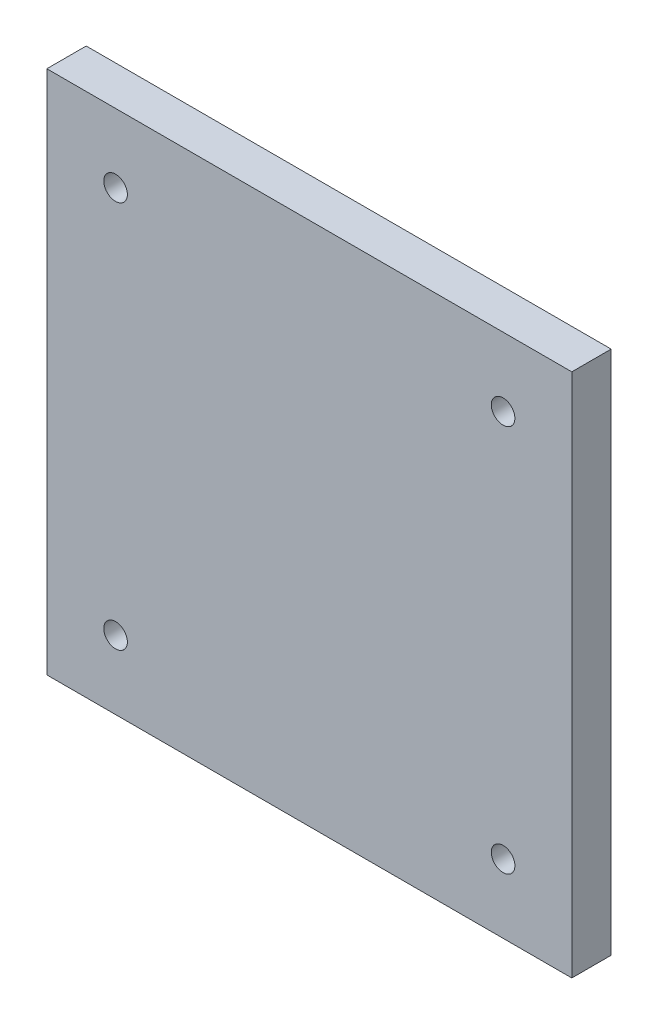
from build123d import *

# Parameters (mm, degrees)
SKETCH1_W           = 101.6
SKETCH1_H           = 101.6
SKETCH1_R           = 2.286
BOSS_EXTRUDE1_DEPTH = 7.62


with BuildPart() as part:
    # Sketch1 → Boss-Extrude1 (new body)
    with BuildSketch(Plane.XY):
        Rectangle(SKETCH1_W, SKETCH1_H)
        with Locations((-37.500052, 37.500052)):
            Circle(SKETCH1_R, mode=Mode.SUBTRACT)
        with Locations((37.500052, 37.500052)):
            Circle(SKETCH1_R, mode=Mode.SUBTRACT)
        with Locations((37.500052, -37.500052)):
            Circle(SKETCH1_R, mode=Mode.SUBTRACT)
        with Locations((-37.500052, -37.500052)):
            Circle(SKETCH1_R, mode=Mode.SUBTRACT)
    extrude(amount=BOSS_EXTRUDE1_DEPTH)


solid = part.part
